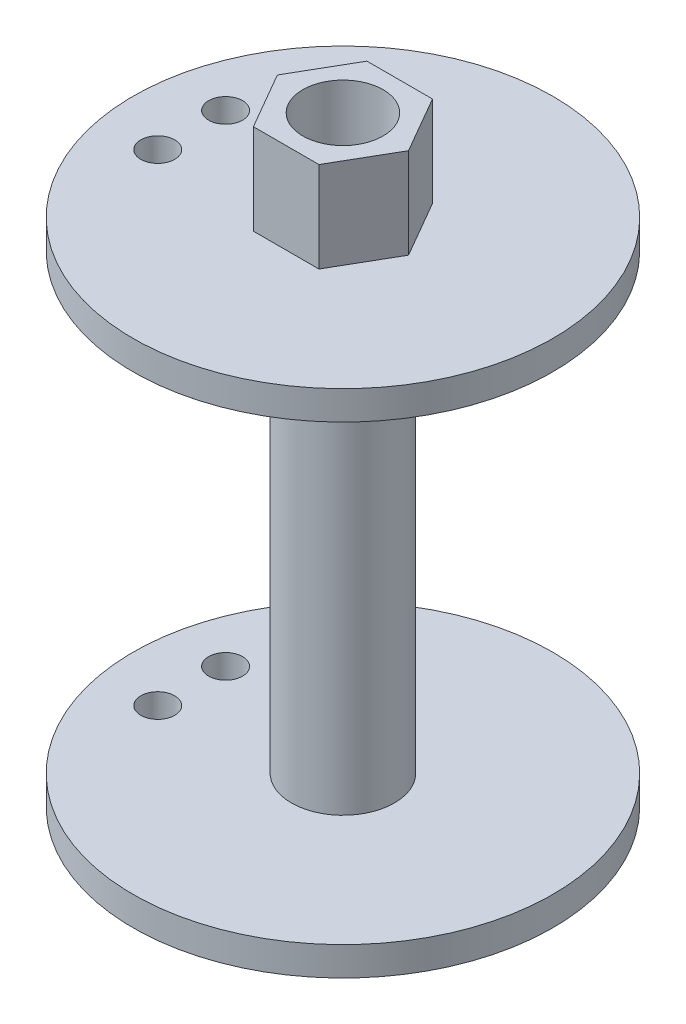
from build123d import *

# Parameters (mm, degrees)
SKETCH1_R               = 18.55
SKETCH1_R_2             = 3.55
BOSS_EXTRUDE1_DEPTH     = 2.56
SKETCH2_R               = 4.55
SKETCH2_R_2             = 3.55
BOSS_EXTRUDE2_DEPTH     = 20
SKETCH5_R               = 18.55
SKETCH5_R_2             = 3.55
BOSS_EXTRUDE3_DEPTH     = 2.56
SKETCH6_R               = 3.55
BOSS_EXTRUDE4_DEPTH     = 8
SKETCH7_R               = 1.5
CUT_EXTRUDE1_DEPTH      = 60.244741539
CUT_EXTRUDE1_DEPTH_BACK = 60.244741539


with BuildPart() as part:
    # Sketch1 → Boss-Extrude1 (new body)
    with BuildSketch(Plane(origin=(0, 0, 0), x_dir=(1, 0, 0), z_dir=(0, 1, 0))):
        with Locations(Location((0, 0, 0), (0, 0, 90))):
            Circle(SKETCH1_R)
        with Locations(Location((0, 0, 0), (0, 0, 90))):
            Circle(SKETCH1_R_2, mode=Mode.SUBTRACT)
    extrude(amount=BOSS_EXTRUDE1_DEPTH)

    # Sketch2 → Boss-Extrude2 (add)
    with BuildSketch(Plane(origin=(0, 2.56, 0), x_dir=(1, 0, 0), z_dir=(0, 1, 0))):
        with Locations(Location((0, 0, 0), (0, 0, 270))):
            Circle(SKETCH2_R)
        with Locations(Location((0, 0, 0), (0, 0, 90))):
            Circle(SKETCH2_R_2, mode=Mode.SUBTRACT)
    boss_extrude2 = extrude(amount=BOSS_EXTRUDE2_DEPTH)

    # Mirror1: Boss-Extrude2 across plane
    add(boss_extrude2.mirror(Plane.ZX.offset(22.56)))

    # Sketch5 → Boss-Extrude3 (add)
    with BuildSketch(Plane(origin=(0, 42.56, 0), x_dir=(1, 0, 0), z_dir=(0, 1, 0))):
        with Locations(Location((0, 0, 0), (0, 0, 90))):
            Circle(SKETCH5_R)
        with Locations(Location((0, 0, 0), (0, 0, 90))):
            Circle(SKETCH5_R_2, mode=Mode.SUBTRACT)
    extrude(amount=BOSS_EXTRUDE3_DEPTH)

    # Sketch6 → Boss-Extrude4 (add)
    with BuildSketch(Plane(origin=(0, 45.12, 0), x_dir=(1, 0, 0), z_dir=(0, 1, 0))):
        Polygon((-5.794958779, 0), (-2.897479389, -5.018581516), (2.897479389, -5.018581516), (5.794958779, 0), (2.897479389, 5.018581516), (-2.897479389, 5.018581516), align=None)
        with Locations(Location((0, 0, 0), (0, 0, 90))):
            Circle(SKETCH6_R, mode=Mode.SUBTRACT)
    extrude(amount=BOSS_EXTRUDE4_DEPTH)

    # Sketch7 → Cut-Extrude1 (cut, two sides)
    with BuildSketch(Plane.XZ) as cut_extrude1_sk:
        with Locations(Location((-13.371154887, -3, 0), (0, 0, 270))):
            Circle(SKETCH7_R)
        with Locations(Location((-13.371154887, 3, 0), (0, 0, 270))):
            Circle(SKETCH7_R)
    extrude(amount=CUT_EXTRUDE1_DEPTH, mode=Mode.SUBTRACT)
    extrude(cut_extrude1_sk.sketch, amount=-CUT_EXTRUDE1_DEPTH_BACK, mode=Mode.SUBTRACT)


solid = part.part
